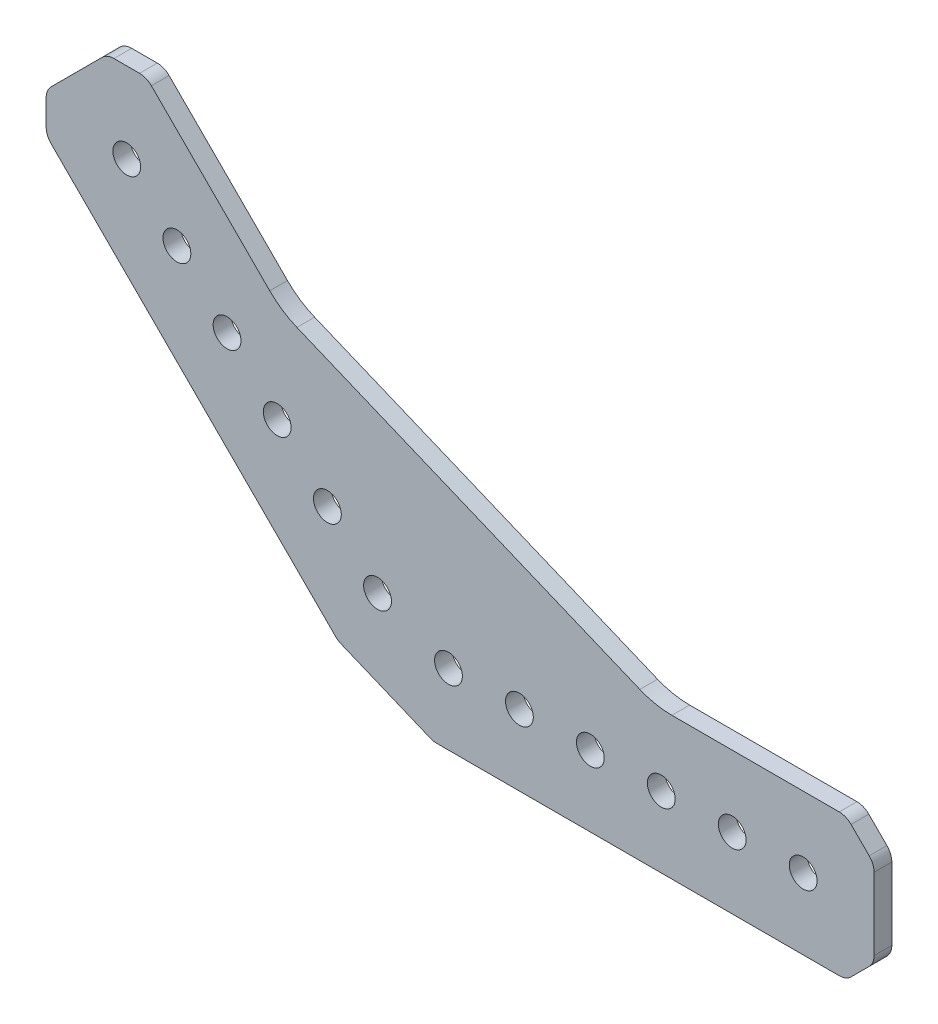
from build123d import *

# Parameters (mm, degrees)
SKETCH1_R           = 2.4892
BOSS_EXTRUDE1_DEPTH = 3.175


with BuildPart() as part:
    # Sketch1 → Boss-Extrude1 (new body)
    with BuildSketch(Plane.XY.offset(3.175)):
        with BuildLine():
            Line((-6.519754617, 6.842706409), (9.448686805, 0.228361402))
            ThreePointArc((9.448686805, 0.228361402), (10.011466136, 0.057644159), (10.596737102, 0))
            Line((10.596737102, 0), (82.657359313, 0))
            ThreePointArc((82.657359313, 0), (83.80540961, 0.228361402), (84.778679656, 0.878679656))
            Line((84.778679656, 0.878679656), (88.021320344, 4.121320344))
            ThreePointArc((88.021320344, 4.121320344), (88.671638598, 5.09459039), (88.9, 6.242640687))
            Line((88.9, 6.242640687), (88.9, 19.157359313))
            ThreePointArc((88.9, 19.157359313), (88.671638598, 20.30540961), (88.021320344, 21.278679656))
            Line((88.021320344, 21.278679656), (84.778679656, 24.521320344))
            ThreePointArc((84.778679656, 24.521320344), (83.80540961, 25.171638598), (82.657359313, 25.4))
            Line((82.657359313, 25.4), (52.701598941, 25.4))
            ThreePointArc((52.701598941, 25.4), (49.775244111, 25.688220794), (46.961347456, 26.541807012))
            Line((46.961347456, 26.541807012), (-14.438795516, 51.974578963))
            ThreePointArc((-14.438795516, 51.974578963), (-17.032097526, 53.360727766), (-19.305145749, 55.226170233))
            Line((-19.305145749, 55.226170233), (-40.487067043, 76.408091527))
            ThreePointArc((-40.487067043, 76.408091527), (-41.460337089, 77.058409781), (-42.608387387, 77.286771184))
            Line((-42.608387387, 77.286771184), (-47.194173824, 77.286771184))
            ThreePointArc((-47.194173824, 77.286771184), (-48.342224121, 77.058409781), (-49.315494168, 76.408091527))
            Line((-49.315494168, 76.408091527), (-58.447579285, 67.27600641))
            ThreePointArc((-58.447579285, 67.27600641), (-59.097897539, 66.302736363), (-59.326258942, 65.154686066))
            Line((-59.326258942, 65.154686066), (-59.326258942, 60.568899629))
            ThreePointArc((-59.326258942, 60.568899629), (-59.097897539, 59.420849332), (-58.447579285, 58.447579285))
            Line((-58.447579285, 58.447579285), (-7.493024663, 7.493024663))
            ThreePointArc((-7.493024663, 7.493024663), (-7.038415019, 7.11993617), (-6.519754617, 6.842706409))
        make_face()
        with Locations((0, 17.960512242)):
            Circle(SKETCH1_R, mode=Mode.SUBTRACT)
        with Locations((12.7, 12.7)):
            Circle(SKETCH1_R, mode=Mode.SUBTRACT)
        with Locations((63.5, 12.7)):
            Circle(SKETCH1_R, mode=Mode.SUBTRACT)
        with Locations((38.1, 12.7)):
            Circle(SKETCH1_R, mode=Mode.SUBTRACT)
        with Locations((-17.960512242, 35.921024484)):
            Circle(SKETCH1_R, mode=Mode.SUBTRACT)
        with Locations((-35.921024484, 53.881536726)):
            Circle(SKETCH1_R, mode=Mode.SUBTRACT)
        with Locations((76.2, 12.7)):
            Circle(SKETCH1_R, mode=Mode.SUBTRACT)
        with Locations((50.8, 12.7)):
            Circle(SKETCH1_R, mode=Mode.SUBTRACT)
        with Locations((25.4, 12.7)):
            Circle(SKETCH1_R, mode=Mode.SUBTRACT)
        with Locations((-8.980256121, 26.940768363)):
            Circle(SKETCH1_R, mode=Mode.SUBTRACT)
        with Locations((-26.940768363, 44.901280605)):
            Circle(SKETCH1_R, mode=Mode.SUBTRACT)
        with Locations((-44.901280605, 62.861792847)):
            Circle(SKETCH1_R, mode=Mode.SUBTRACT)
    extrude(amount=-BOSS_EXTRUDE1_DEPTH)


solid = part.part
